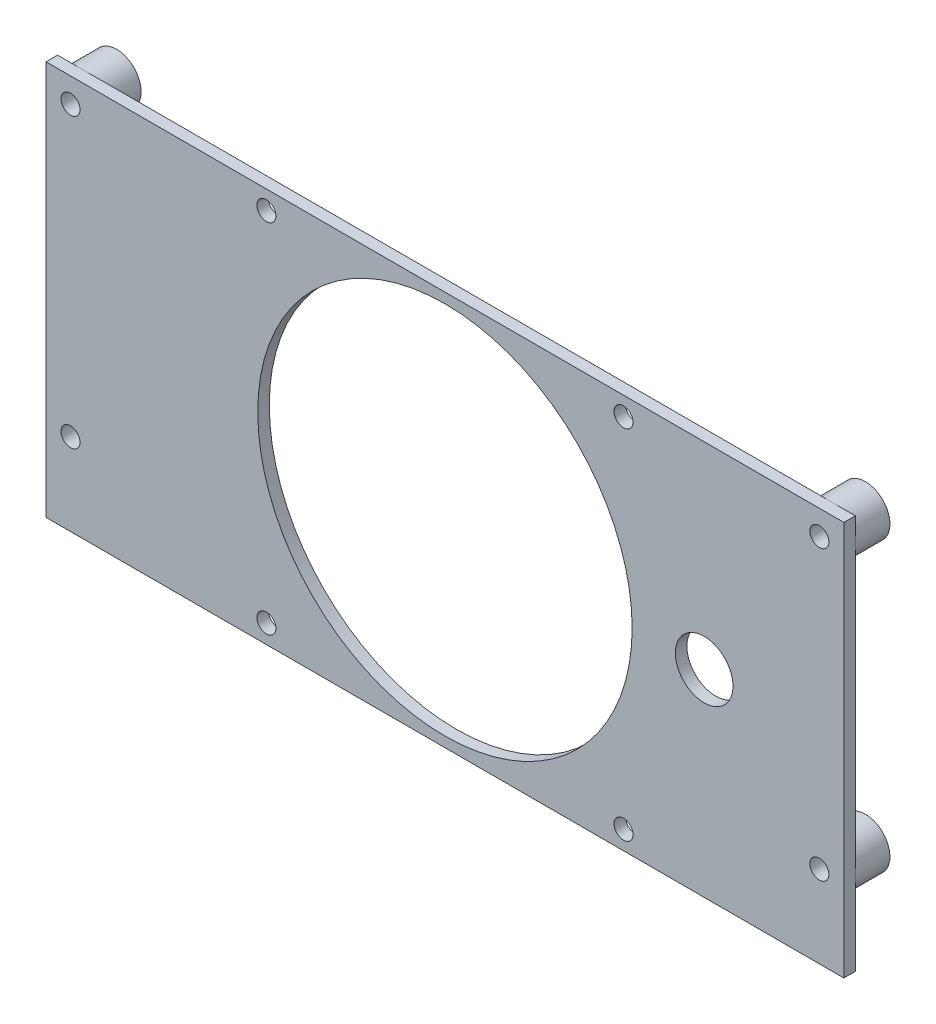
from build123d import *

# Parameters (mm, degrees)
ESBO_O1_W                = 138.5
ESBO_O1_H                = 68.5
ESBO_O1_R                = 1.65
ESBO_O1_R_2              = 32.5
ESBO_O1_R_3              = 5
RESSALTO_EXTRUS_O1_DEPTH = 2
ESBO_O2_R                = 4.25
ESBO_O2_R_2              = 1.65
RESSALTO_EXTRUS_O2_DEPTH = 6


with BuildPart() as part:
    # Esboço1 → Ressalto-extrusão1 (new body)
    with BuildSketch(Plane.XY):
        Rectangle(ESBO_O1_W, ESBO_O1_H)
        with Locations((-65, 30)):
            Circle(ESBO_O1_R, mode=Mode.SUBTRACT)
        with Locations((-65, -20)):
            Circle(ESBO_O1_R, mode=Mode.SUBTRACT)
        with Locations((65, -20)):
            Circle(ESBO_O1_R, mode=Mode.SUBTRACT)
        with Locations((65, 30)):
            Circle(ESBO_O1_R, mode=Mode.SUBTRACT)
        Circle(ESBO_O1_R_2, mode=Mode.SUBTRACT)
        with Locations((-31, 31)):
            Circle(ESBO_O1_R, mode=Mode.SUBTRACT)
        with Locations((-31, -31)):
            Circle(ESBO_O1_R, mode=Mode.SUBTRACT)
        with Locations((31, -31)):
            Circle(ESBO_O1_R, mode=Mode.SUBTRACT)
        with Locations((31, 31)):
            Circle(ESBO_O1_R, mode=Mode.SUBTRACT)
        with Locations((45, 0)):
            Circle(ESBO_O1_R_3, mode=Mode.SUBTRACT)
    extrude(amount=RESSALTO_EXTRUS_O1_DEPTH)

    # Esboço2 → Ressalto-extrusão2 (add)
    with BuildSketch(Plane(origin=(0, 0, 0), x_dir=(-1, 0, 0), z_dir=(0, 0, -1))):
        with Locations((65, 30)):
            Circle(ESBO_O2_R)
        with Locations((65, 30)):
            Circle(ESBO_O2_R_2, mode=Mode.SUBTRACT)
        with Locations((65, -20)):
            Circle(ESBO_O2_R)
        with Locations((65, -20)):
            Circle(ESBO_O2_R_2, mode=Mode.SUBTRACT)
        with Locations((-65, -20)):
            Circle(ESBO_O2_R)
        with Locations((-65, -20)):
            Circle(ESBO_O2_R_2, mode=Mode.SUBTRACT)
        with Locations((-65, 30)):
            Circle(ESBO_O2_R)
        with Locations((-65, 30)):
            Circle(ESBO_O2_R_2, mode=Mode.SUBTRACT)
    extrude(amount=RESSALTO_EXTRUS_O2_DEPTH)


solid = part.part
